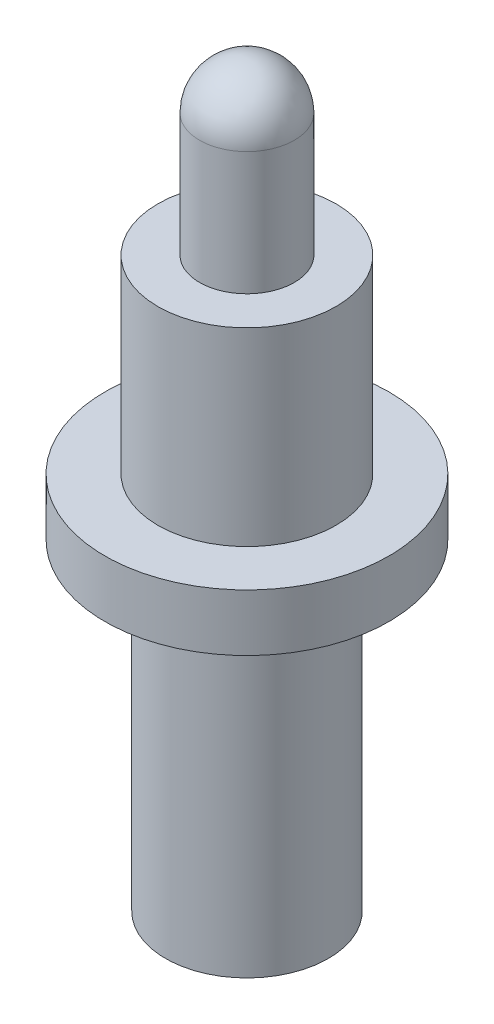
from build123d import *


with BuildPart() as part:
    # Sketch1 → Revolve1 (revolve)
    with BuildSketch(Plane(origin=(0, 0, 0), x_dir=(0, 0, -1), z_dir=(1, 0, 0))):
        with BuildLine():
            Line((0.635, 7.62), (1.1938, 7.62))
            Line((1.1938, 7.62), (1.1938, 5.08))
            Line((1.1938, 5.08), (1.905, 5.08))
            Line((1.905, 5.08), (1.905, 4.318))
            Line((1.905, 4.318), (1.0922, 4.318))
            Line((1.0922, 4.318), (1.0922, 0))
            Line((1.0922, 0), (0, 0))
            Line((0, 0), (0, 9.906))
            ThreePointArc((0, 9.906), (0.449012806, 9.720012806), (0.635, 9.271))
            Line((0.635, 9.271), (0.635, 7.62))
        make_face()
    revolve(axis=Axis((0, 0, 0), (0, 1, 0)))


solid = part.part
